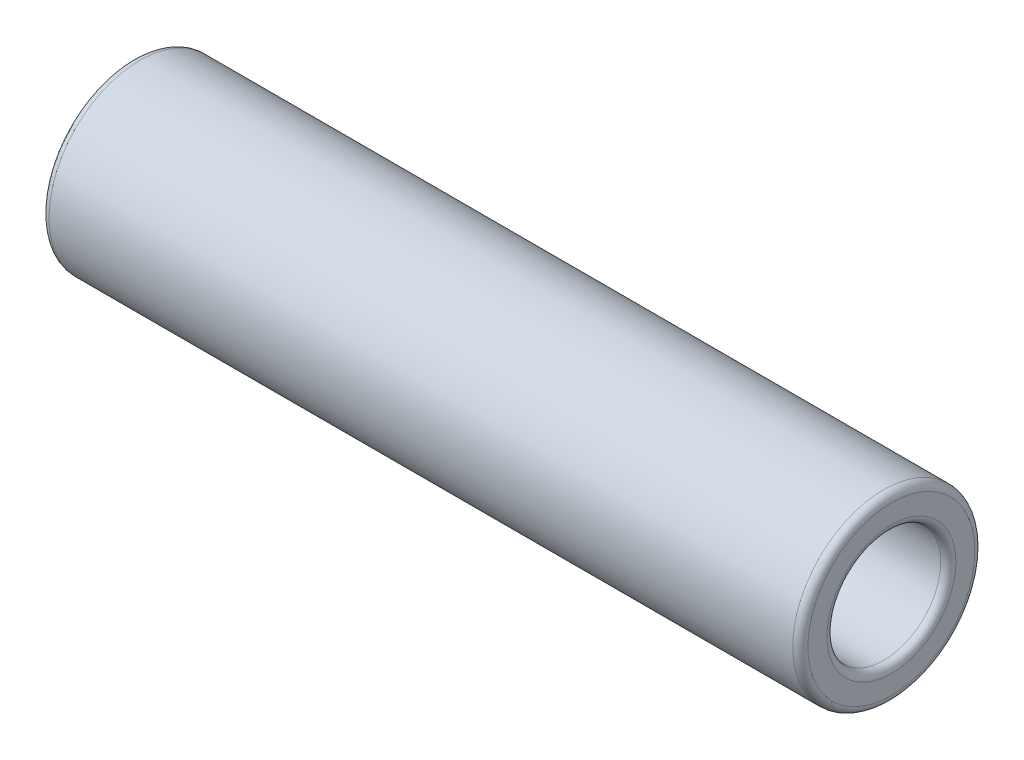
from build123d import *

# Parameters (mm, degrees)
SKETCH1_R           = 6
SKETCH1_R_2         = 3.75
BOSS_EXTRUDE1_DEPTH = 50
FILLET1_R           = 0.5


with BuildPart() as part:
    # Sketch1 → Boss-Extrude1 (new body)
    with BuildSketch(Plane(origin=(0, 0, 0), x_dir=(0, 0, -1), z_dir=(1, 0, 0))):
        Circle(SKETCH1_R)
        Circle(SKETCH1_R_2, mode=Mode.SUBTRACT)
    extrude(amount=BOSS_EXTRUDE1_DEPTH)

    # Fillet1
    fillet1_edges = [part.edges().sort_by_distance(p)[0] for p in [
        (0, 0, 6),
        (50, 0, 6),
        (0, 0, 3.75),
        (50, 0, 3.75),
    ]]
    fillet(fillet1_edges, radius=FILLET1_R)


solid = part.part
